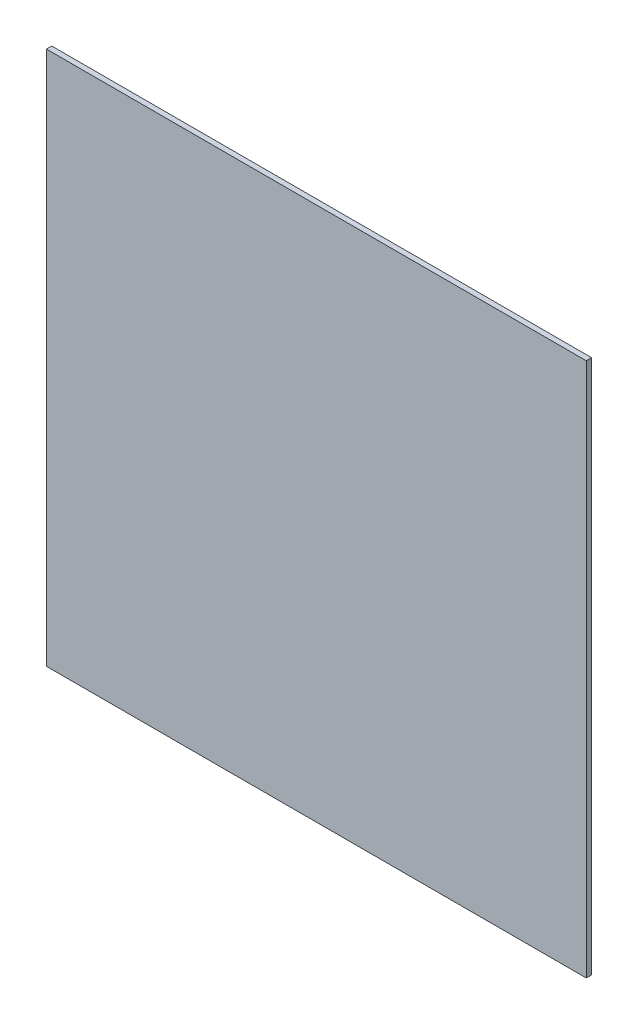
from build123d import *

# Parameters (mm, degrees)
CROQUIS1_W              = 305
CROQUIS1_H              = 302
SALIENTE_EXTRUIR1_DEPTH = 3


with BuildPart() as part:
    # Croquis1 → Saliente-Extruir1 (new body)
    with BuildSketch(Plane.XY):
        with Locations((152.5, 151)):
            Rectangle(CROQUIS1_W, CROQUIS1_H)
    extrude(amount=SALIENTE_EXTRUIR1_DEPTH)


solid = part.part
